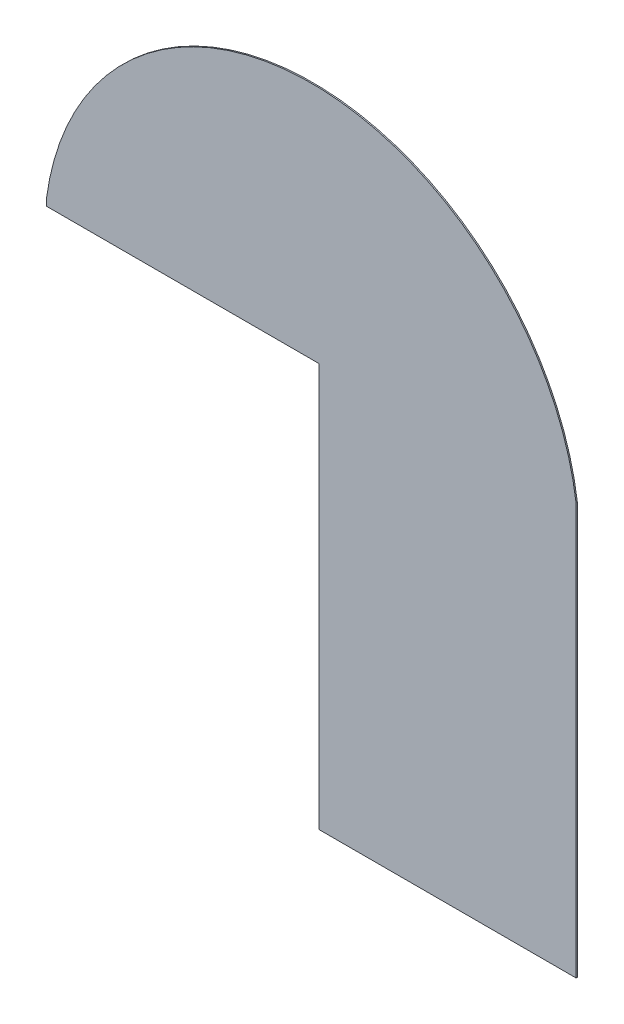
from build123d import *

# Parameters (mm, degrees)
BOSS_EXTRUDE1_DEPTH = 2.5
SKETCH2_W           = 1060
SKETCH2_H           = 1570
CUT_EXTRUDE2_DEPTH  = 6


with BuildPart() as part:
    # Sketch1 → Boss-Extrude1 (new body, symmetric)
    with BuildSketch(Plane.XY):
        with BuildLine():
            Line((1030, 800), (1030, -800))
            Line((1030, -800), (-1030, -800))
            Line((-1030, -800), (-1030, 800))
            ThreePointArc((-1030, 800), (0, 1700), (1030, 800))
        make_face()
    extrude(amount=BOSS_EXTRUDE1_DEPTH, both=True)

    # Sketch2 → Cut-Extrude2 (cut, through all)
    with BuildSketch(Plane.XY.offset(2.5)):
        with Locations((-500, -15)):
            Rectangle(SKETCH2_W, SKETCH2_H)
    extrude(amount=-CUT_EXTRUDE2_DEPTH, mode=Mode.SUBTRACT)


solid = part.part
